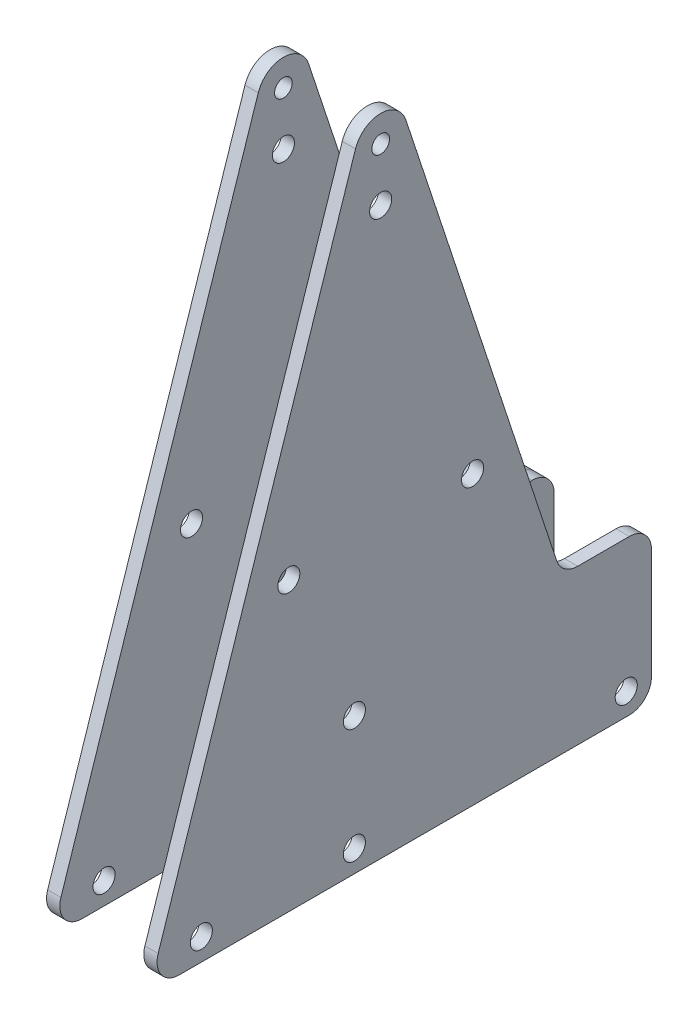
from build123d import *

# Parameters (mm, degrees)
BOSS_EXTRUDE1_DEPTH            = 3
F_4_0MM_DOWEL_HOLE1_D          = 4
SKETCH5_W                      = 41.17320508
SKETCH5_H                      = 20.8
CUT_EXTRUDE1_DEPTH             = 8.5
BOSS_EXTRUDE2_DEPTH            = 6.2
SKETCH12_W                     = 41.17320508
SKETCH12_H                     = 20.8
BOSS_EXTRUDE6_DEPTH            = 3.8
CUT_EXTRUDE2_START             = -10
SKETCH15_R                     = 2
SKETCH15_R_2                   = 2.5
CUT_EXTRUDE2_DEPTH             = 10
SKETCH16_R                     = 2.5
CUT_EXTRUDE3_DEPTH             = 3
SKETCH17_W                     = 41.17320508
SKETCH17_H                     = 9.6
BOSS_EXTRUDE8_DEPTH            = 24.2
SKETCH20_W                     = 2.5
SKETCH20_H                     = 25
F_5_0MM_DOWEL_HOLE1_AT_2_COUNT = 2
F_5_0MM_DOWEL_HOLE1_AT_2_PITCH = 66.339181814
F_5_0MM_DOWEL_HOLE1_AT_3_COUNT = 2
F_5_0MM_DOWEL_HOLE1_AT_3_PITCH = 66.339181814
F_5_0MM_DOWEL_HOLE1_AT_4_COUNT = 2
F_5_0MM_DOWEL_HOLE1_AT_4_PITCH = 134.962226197
F_5_0MM_DOWEL_HOLE1_AT_5_COUNT = 2
F_5_0MM_DOWEL_HOLE1_AT_5_PITCH = 123.14382851
F_5_0MM_DOWEL_HOLE1_AT_6_COUNT = 2
F_5_0MM_DOWEL_HOLE1_AT_6_PITCH = 129.51935497
F_5_0MM_DOWEL_HOLE1_AT_7_COUNT = 2
F_5_0MM_DOWEL_HOLE1_AT_7_PITCH = 97.182315778
CUT_EXTRUDE4_DEPTH             = 6.2


with BuildPart() as part:
    # Sketch3 → Boss-Extrude1 (new body)
    with BuildSketch(Plane(origin=(9.5, 0, 0), x_dir=(0, 0, -1), z_dir=(1, 0, 0))):
        with BuildLine():
            ThreePointArc((-5.697990082, 141.879603423), (0, 146), (5.697990082, 141.879603423))
            Line((5.697990082, 141.879603423), (39.821837166, 38.433663814))
            ThreePointArc((39.821837166, 38.433663814), (41.640288596, 35.948353364), (44.570162234, 35))
            Line((44.570162234, 35), (56.25, 35))
            ThreePointArc((56.25, 35), (59.785533906, 33.535533906), (61.25, 30))
            Line((61.25, 30), (61.25, 5))
            ThreePointArc((61.25, 5), (59.785533906, 1.464466094), (56.25, 0))
            Line((56.25, 0), (0, 0))
            Line((0, 0), (-45.585629046, 0))
            ThreePointArc((-45.585629046, 0), (-49.637275682, 2.070126362), (-50.333954114, 6.566336186))
            Line((-50.333954114, 6.566336186), (-5.697990082, 141.879603423))
        make_face()
    extrude(amount=BOSS_EXTRUDE1_DEPTH)

    # Ø4.0mm Dowel Hole1 (through all)
    with Locations(Plane(origin=(12.5, 0, 0), x_dir=(0, 0, -1), z_dir=(1, 0, 0))):
        with Locations((0, 140)):
            Hole(F_4_0MM_DOWEL_HOLE1_D / 2)


with BuildPart() as body_2:
    # Mirror2: mirrored copy
    add(part.part.mirror(Plane(origin=(0, 0, 0), x_dir=(0, 0, 1), z_dir=(1, 0, 0))))

    # Sketch5 → Cut-Extrude1 (cut)
    with BuildSketch(Plane.ZY.offset(18)):
        with Locations((-24.8, 20)):
            Rectangle(SKETCH5_W, SKETCH5_H)
    extrude(amount=-CUT_EXTRUDE1_DEPTH, mode=Mode.SUBTRACT)

    # Sketch16 → Cut-Extrude3 (cut)
    with BuildSketch(Plane.ZY.offset(12.5)):
        with Locations((5.95, 31)):
            Circle(SKETCH16_R)
        with Locations((5.95, 5)):
            Circle(SKETCH16_R)
        with Locations((-55.55, 5)):
            Circle(SKETCH16_R)
    extrude(amount=-CUT_EXTRUDE3_DEPTH, mode=Mode.SUBTRACT)


with BuildPart() as body_3:
    # Sketch11 → Boss-Extrude2 (new body)
    with BuildSketch(Plane.ZY.offset(12.5)):
        with BuildLine():
            ThreePointArc((-61.25, 5), (-59.785533906, 1.464466094), (-56.25, 0))
            Line((-56.25, 0), (10.35, 0))
            Line((10.35, 0), (10.35, 35))
            Line((10.35, 35), (-56.25, 35))
            ThreePointArc((-56.25, 35), (-59.785533906, 33.535533906), (-61.25, 30))
            Line((-61.25, 30), (-61.25, 5))
        make_face()
        Polygon((2.35, 30.4), (2.35, 9.8), (-4.21339746, 9.8), (-4.21339746, 9.6), (-45.38660254, 9.6), (-45.38660254, 9.8), (-51.95, 9.8), (-51.95, 30.4), align=None, mode=Mode.SUBTRACT)
    extrude(amount=BOSS_EXTRUDE2_DEPTH)

    # Sketch12 → Boss-Extrude6 (add)
    with BuildSketch(Plane.ZY.offset(18.7)):
        with BuildLine():
            ThreePointArc((-61.25, 5), (-59.785533906, 1.464466094), (-56.25, 0))
            Line((-56.25, 0), (10.35, 0))
            Line((10.35, 0), (10.35, 35))
            Line((10.35, 35), (-56.25, 35))
            ThreePointArc((-56.25, 35), (-59.785533906, 33.535533906), (-61.25, 30))
            Line((-61.25, 30), (-61.25, 5))
        make_face()
        with Locations((-24.8, 20)):
            Rectangle(SKETCH12_W, SKETCH12_H, mode=Mode.SUBTRACT)
    extrude(amount=BOSS_EXTRUDE6_DEPTH)

    # Sketch15 → Cut-Extrude2 (cut)
    with BuildSketch(Plane.ZY.offset(22.5).offset(CUT_EXTRUDE2_START)):
        with Locations((-0.55, 15)):
            Circle(SKETCH15_R)
        with Locations((-49.05, 15)):
            Circle(SKETCH15_R)
        with Locations((-49.05, 25)):
            Circle(SKETCH15_R)
        with Locations((-0.55, 25)):
            Circle(SKETCH15_R)
        with Locations((5.95, 31)):
            Circle(SKETCH15_R_2)
        with Locations((-55.55, 5)):
            Circle(SKETCH15_R_2)
        with Locations((5.95, 5)):
            Circle(SKETCH15_R_2)
    extrude(amount=CUT_EXTRUDE2_DEPTH, mode=Mode.SUBTRACT)

    # Sketch17 → Boss-Extrude8 (add)
    with BuildSketch(Plane.ZY.offset(22.5)):
        with Locations((-24.8, 4.8)):
            Rectangle(SKETCH17_W, SKETCH17_H)
    extrude(amount=BOSS_EXTRUDE8_DEPTH)

    # Sketch21 → Cut-Extrude4 (cut)
    with BuildSketch(Plane(origin=(-12.5, 0, 0), x_dir=(0, 0, -1), z_dir=(1, 0, 0))):
        with BuildLine():
            ThreePointArc((51.95, 21.893152723), (52.94791611, 23.306261531), (53.3, 25))
            ThreePointArc((53.3, 25), (52.94791611, 26.693738469), (51.95, 28.106847277))
            Line((51.95, 28.106847277), (51.95, 21.893152723))
        make_face()
        with BuildLine():
            ThreePointArc((53.3, 15), (52.94791611, 16.693738469), (51.95, 18.106847277))
            Line((51.95, 18.106847277), (51.95, 11.893152723))
            ThreePointArc((51.95, 11.893152723), (52.94791611, 13.306261531), (53.3, 15))
        make_face()
        with BuildLine():
            Line((-2.35, 21.893152723), (-2.35, 28.106847277))
            ThreePointArc((-2.35, 28.106847277), (-3.7, 25), (-2.35, 21.893152723))
        make_face()
        with BuildLine():
            Line((-2.35, 11.893152723), (-2.35, 18.106847277))
            ThreePointArc((-2.35, 18.106847277), (-3.7, 15), (-2.35, 11.893152723))
        make_face()
    extrude(amount=-CUT_EXTRUDE4_DEPTH, mode=Mode.SUBTRACT)


with BuildPart() as f_5_0mm_dowel_hole1_tool:
    # Sketch20 → Ø5.0mm Dowel Hole1 (revolve)
    with BuildSketch(Plane(origin=(-12.5, 128, 0), x_dir=(0, 0, 1), z_dir=(0, 1, 0))):
        with Locations((1.25, 12.5)):
            Rectangle(SKETCH20_W, SKETCH20_H)
    f_5_0mm_dowel_hole1 = revolve(axis=Axis((-18.85, 128, 0), (1, 0, 0)))


with BuildPart() as part_1:
    add(part.part)

    # Ø5.0mm Dowel Hole1: cut by f_5_0mm_dowel_hole1_tool
    add(f_5_0mm_dowel_hole1_tool.part, mode=Mode.SUBTRACT)


with BuildPart() as body_2_1:
    add(body_2.part)

    # Ø5.0mm Dowel Hole1: cut by f_5_0mm_dowel_hole1_tool
    add(f_5_0mm_dowel_hole1_tool.part, mode=Mode.SUBTRACT)


with BuildPart() as f_5_0mm_dowel_hole1_at_2_tool:
    # Ø5.0mm Dowel Hole1 at 2: Ø5.0mm Dowel Hole1 ×2
    with Locations(*[Vector(0, -0.9496650136067186, -0.31326723724537664) * (i * F_5_0MM_DOWEL_HOLE1_AT_2_PITCH) for i in range(1, F_5_0MM_DOWEL_HOLE1_AT_2_COUNT)]):
        add(f_5_0mm_dowel_hole1)


with BuildPart() as part_2:
    add(part_1.part)

    # Ø5.0mm Dowel Hole1 at 2: cut by f_5_0mm_dowel_hole1_at_2_tool
    add(f_5_0mm_dowel_hole1_at_2_tool.part, mode=Mode.SUBTRACT)


with BuildPart() as body_2_2:
    add(body_2_1.part)

    # Ø5.0mm Dowel Hole1 at 2: cut by f_5_0mm_dowel_hole1_at_2_tool
    add(f_5_0mm_dowel_hole1_at_2_tool.part, mode=Mode.SUBTRACT)


with BuildPart() as f_5_0mm_dowel_hole1_at_3_tool:
    # Ø5.0mm Dowel Hole1 at 3: Ø5.0mm Dowel Hole1 ×2
    with Locations(*[Vector(0, -0.9496650136067186, 0.31326723724537664) * (i * F_5_0MM_DOWEL_HOLE1_AT_3_PITCH) for i in range(1, F_5_0MM_DOWEL_HOLE1_AT_3_COUNT)]):
        add(f_5_0mm_dowel_hole1)


with BuildPart() as part_3:
    add(part_2.part)

    # Ø5.0mm Dowel Hole1 at 3: cut by f_5_0mm_dowel_hole1_at_3_tool
    add(f_5_0mm_dowel_hole1_at_3_tool.part, mode=Mode.SUBTRACT)

    # Ø5.0mm Dowel Hole1 at 4: Ø5.0mm Dowel Hole1 ×2
    with Locations(*[Vector(0, -0.9113661167727802, -0.4115966486725849) * (i * F_5_0MM_DOWEL_HOLE1_AT_4_PITCH) for i in range(1, F_5_0MM_DOWEL_HOLE1_AT_4_COUNT)]):
        add(f_5_0mm_dowel_hole1, mode=Mode.SUBTRACT)

    # Ø5.0mm Dowel Hole1 at 5: Ø5.0mm Dowel Hole1 ×2
    with Locations(*[Vector(0, -0.9988320282767431, 0.048317484294687886) * (i * F_5_0MM_DOWEL_HOLE1_AT_5_PITCH) for i in range(1, F_5_0MM_DOWEL_HOLE1_AT_5_COUNT)]):
        add(f_5_0mm_dowel_hole1, mode=Mode.SUBTRACT)


with BuildPart() as body_2_3:
    add(body_2_2.part)

    # Ø5.0mm Dowel Hole1 at 3: cut by f_5_0mm_dowel_hole1_at_3_tool
    add(f_5_0mm_dowel_hole1_at_3_tool.part, mode=Mode.SUBTRACT)


with BuildPart() as f_5_0mm_dowel_hole1_at_6_tool:
    # Ø5.0mm Dowel Hole1 at 6: Ø5.0mm Dowel Hole1 ×2
    with Locations(*[Vector(0, -0.9496650136067186, 0.3132672372453767) * (i * F_5_0MM_DOWEL_HOLE1_AT_6_PITCH) for i in range(1, F_5_0MM_DOWEL_HOLE1_AT_6_COUNT)]):
        add(f_5_0mm_dowel_hole1)


with BuildPart() as part_4:
    add(part_3.part)

    # Ø5.0mm Dowel Hole1 at 6: cut by f_5_0mm_dowel_hole1_at_6_tool
    add(f_5_0mm_dowel_hole1_at_6_tool.part, mode=Mode.SUBTRACT)

    # Ø5.0mm Dowel Hole1 at 7: Ø5.0mm Dowel Hole1 ×2
    with Locations(*[Vector(0, -0.998123981954234, 0.06122513085183183) * (i * F_5_0MM_DOWEL_HOLE1_AT_7_PITCH) for i in range(1, F_5_0MM_DOWEL_HOLE1_AT_7_COUNT)]):
        add(f_5_0mm_dowel_hole1, mode=Mode.SUBTRACT)


with BuildPart() as body_2_4:
    add(body_2_3.part)

    # Ø5.0mm Dowel Hole1 at 6: cut by f_5_0mm_dowel_hole1_at_6_tool
    add(f_5_0mm_dowel_hole1_at_6_tool.part, mode=Mode.SUBTRACT)


solid = Compound([body_3.part, part_4.part, body_2_4.part])
